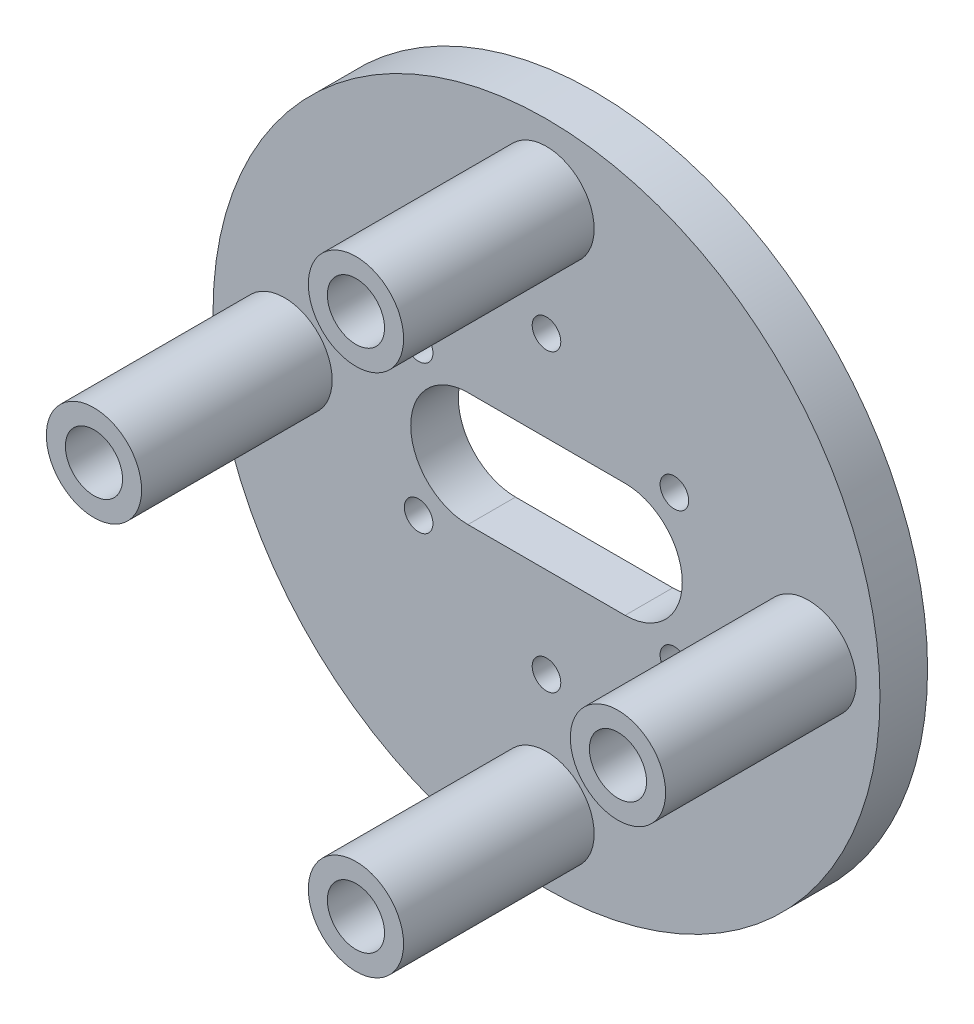
from build123d import *

# Parameters (mm, degrees)
ESBO_O1_R                = 35
RESSALTO_EXTRUS_O1_DEPTH = 5
ESBO_O2_R                = 5
RESSALTO_EXTRUS_O2_DEPTH = 20
ESBO_O3_R                = 3
CORTE_EXTRUS_O1_DEPTH    = 5
CORTE_EXTRUS_O2_DEPTH    = 14
ESBO_O5_R                = 1.5
CORTE_EXTRUS_O3_DEPTH    = 14


with BuildPart() as part:
    # Esboço1 → Ressalto-extrusão1 (new body)
    with BuildSketch(Plane.XY):
        Circle(ESBO_O1_R)
    extrude(amount=RESSALTO_EXTRUS_O1_DEPTH)

    # Esboço2 → Ressalto-extrusão2 (add)
    with BuildSketch(Plane.XY.offset(5)):
        with Locations((27.5, 0)):
            Circle(ESBO_O2_R)
        with Locations((0, -27.5)):
            Circle(ESBO_O2_R)
        with Locations((0, 27.5)):
            Circle(ESBO_O2_R)
        with Locations((-27.5, 0)):
            Circle(ESBO_O2_R)
    extrude(amount=RESSALTO_EXTRUS_O2_DEPTH)

    # Esboço3 → Corte-extrusão1 (cut)
    with BuildSketch(Plane.XY.offset(25)):
        with Locations((0, 27.5)):
            Circle(ESBO_O3_R)
        with Locations((27.5, 0)):
            Circle(ESBO_O3_R)
        with Locations((0, -27.5)):
            Circle(ESBO_O3_R)
        with Locations((-27.5, 0)):
            Circle(ESBO_O3_R)
    extrude(amount=-CORTE_EXTRUS_O1_DEPTH, mode=Mode.SUBTRACT)

    # Esboço4 → Corte-extrusão2 (cut)
    with BuildSketch(Plane.XY.offset(5)):
        with BuildLine():
            Line((8.25, 6), (-8.25, 6))
            ThreePointArc((-8.25, 6), (-14.25, 0), (-8.25, -6))
            Line((-8.25, -6), (8.25, -6))
            ThreePointArc((8.25, -6), (14.25, 0), (8.25, 6))
        make_face()
    extrude(amount=-CORTE_EXTRUS_O2_DEPTH, mode=Mode.SUBTRACT)

    # Esboço5 → Corte-extrusão3 (cut)
    with BuildSketch(Plane.XY.offset(5)):
        with Locations((13.423393759, 7.75)):
            Circle(ESBO_O5_R)
        with Locations((13.423393759, -7.75)):
            Circle(ESBO_O5_R)
        with Locations((0, -15.5)):
            Circle(ESBO_O5_R)
        with Locations((-13.423393759, -7.75)):
            Circle(ESBO_O5_R)
        with Locations((-13.423393759, 7.75)):
            Circle(ESBO_O5_R)
        with Locations((0, 15.5)):
            Circle(ESBO_O5_R)
    extrude(amount=-CORTE_EXTRUS_O3_DEPTH, mode=Mode.SUBTRACT)


solid = part.part
